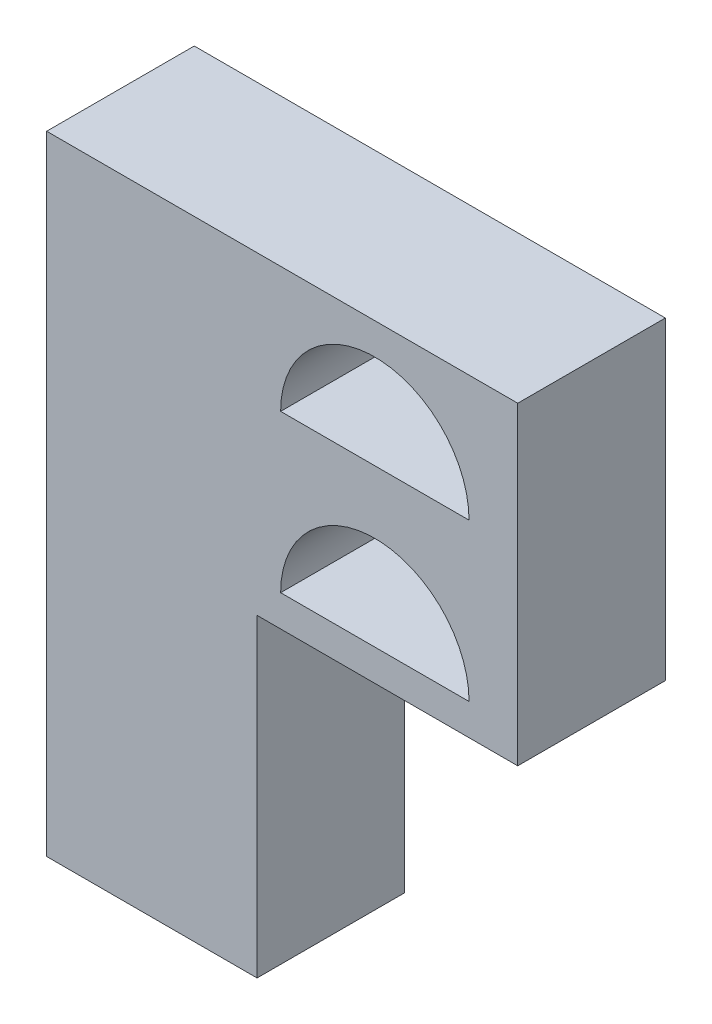
from build123d import *

# Parameters (mm, degrees)
BOSS_EXTRUDE2_DEPTH = 4.7
SKETCH4_W           = 3
SKETCH4_H           = 3.5
CUT_EXTRUDE1_DEPTH  = 5


with BuildPart() as part:
    # Sketch3 → Boss-Extrude2 (new body)
    with BuildSketch(Plane.XY):
        Polygon((-3.35, 5), (-3.35, -5), (3.35, -5), (3.35, 5), (6.63, 5), (10.65, 5), (11.65, 5), (11.65, 15), (10.65, 15), (-3.35, 15), align=None)
        with BuildLine():
            Line((10.1, 11), (4.1, 11))
            ThreePointArc((4.1, 11), (7.1, 14), (10.1, 11))
        make_face(mode=Mode.SUBTRACT)
        with BuildLine():
            Line((10.1, 6), (4.1, 6))
            ThreePointArc((4.1, 6), (7.1, 9), (10.1, 6))
        make_face(mode=Mode.SUBTRACT)
    extrude(amount=BOSS_EXTRUDE2_DEPTH)

    # Sketch4 → Cut-Extrude1 (cut)
    with BuildSketch(Plane.ZY.offset(3.35)):
        with Locations((2.35, 7.597247867)):
            Rectangle(SKETCH4_W, SKETCH4_H)
        with Locations((2.35, 12.597247867)):
            Rectangle(SKETCH4_W, SKETCH4_H)
    extrude(amount=-CUT_EXTRUDE1_DEPTH, mode=Mode.SUBTRACT)


solid = part.part
